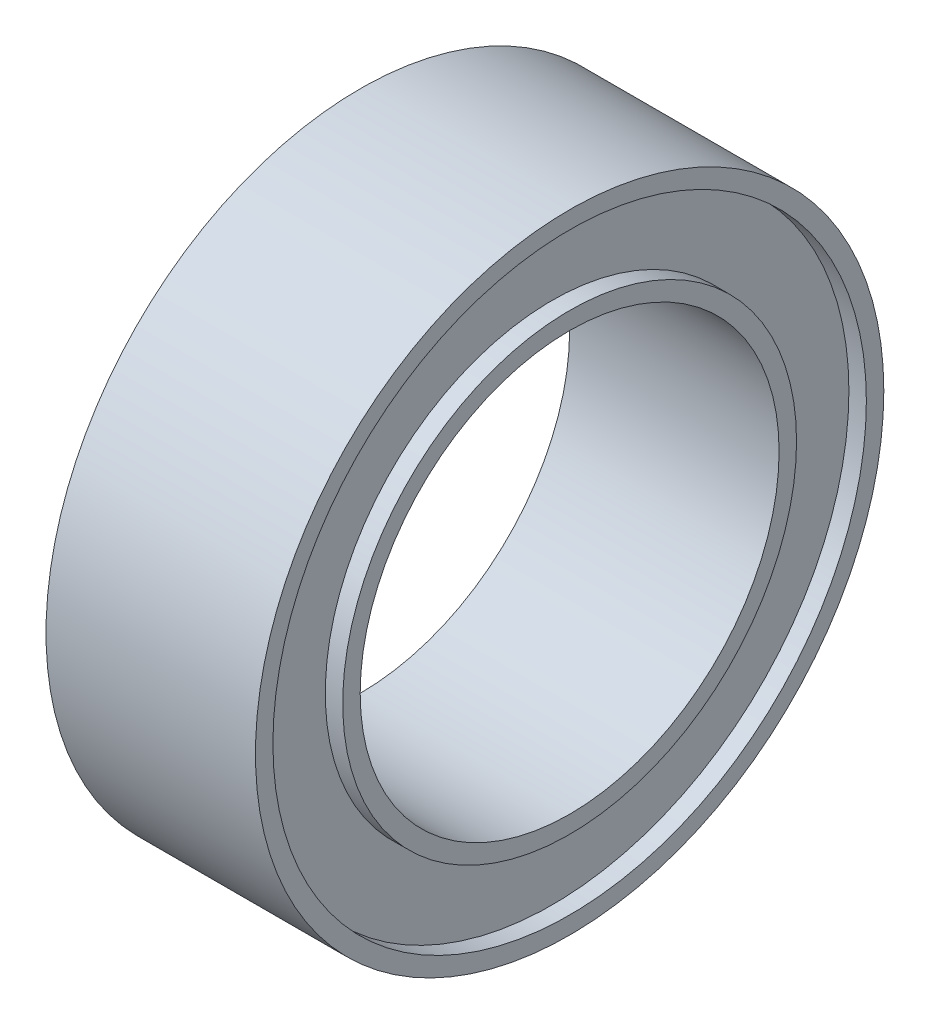
from build123d import *

# Parameters (mm, degrees)
SKETCH2_R           = 9
BOSS_EXTRUDE1_DEPTH = 3
SKETCH3_R           = 6
CUT_EXTRUDE1_DEPTH  = 6
SKETCH4_R           = 8.5
SKETCH4_R_2         = 7.5
SKETCH4_R_3         = 6.5
CUT_EXTRUDE2_DEPTH  = 0.5


with BuildPart() as part:
    # Sketch2 → Boss-Extrude1 (new, symmetric)
    with BuildSketch(Plane(origin=(0, 0, 0), x_dir=(0, 0, -1), z_dir=(1, 0, 0))):
        Circle(SKETCH2_R)
    extrude(amount=BOSS_EXTRUDE1_DEPTH, both=True)

    # Sketch3 → Cut-Extrude1 (cut)
    with BuildSketch(Plane(origin=(3, 0, 0), x_dir=(0, 0, -1), z_dir=(1, 0, 0))):
        Circle(SKETCH3_R)
    extrude(amount=-CUT_EXTRUDE1_DEPTH, mode=Mode.SUBTRACT)

    # Sketch4 → Cut-Extrude2 (cut)
    with BuildSketch(Plane(origin=(3, 0, 0), x_dir=(0, 0, -1), z_dir=(1, 0, 0))):
        Circle(SKETCH4_R)
        Circle(SKETCH4_R_2, mode=Mode.SUBTRACT)
        Circle(SKETCH4_R_2)
        Circle(SKETCH4_R_3, mode=Mode.SUBTRACT)
    cut_extrude2 = extrude(amount=-CUT_EXTRUDE2_DEPTH, mode=Mode.SUBTRACT)

    # Mirror1: Cut-Extrude2 across plane
    add(cut_extrude2.mirror(Plane(origin=(0, 0, 0), x_dir=(0, 0, 1), z_dir=(1, 0, 0))), mode=Mode.SUBTRACT)


solid = part.part
